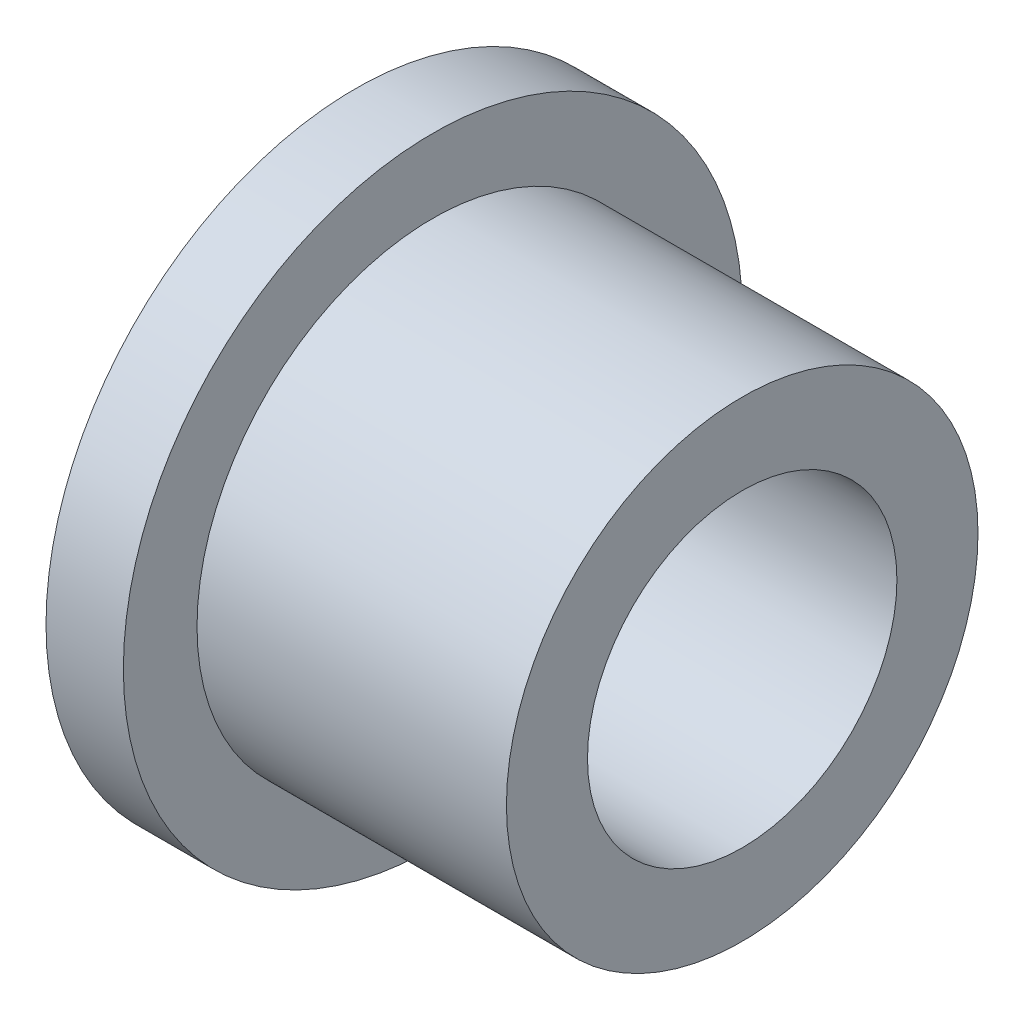
from build123d import *

# Parameters (mm, degrees)
SKETCH1_R           = 6.35
SKETCH1_R_2         = 3.175
BOSS_EXTRUDE1_DEPTH = 1.5875
SKETCH2_R           = 4.8387
SKETCH2_R_2         = 3.175
BOSS_EXTRUDE2_DEPTH = 6.35


with BuildPart() as part:
    # Sketch1 → Boss-Extrude1 (new body)
    with BuildSketch(Plane(origin=(0, 0, 0), x_dir=(0, 0, -1), z_dir=(1, 0, 0))):
        Circle(SKETCH1_R)
        Circle(SKETCH1_R_2, mode=Mode.SUBTRACT)
    extrude(amount=BOSS_EXTRUDE1_DEPTH)

    # Sketch2 → Boss-Extrude2 (add)
    with BuildSketch(Plane(origin=(1.5875, 0, 0), x_dir=(0, 0, -1), z_dir=(1, 0, 0))):
        Circle(SKETCH2_R)
        Circle(SKETCH2_R_2, mode=Mode.SUBTRACT)
    extrude(amount=BOSS_EXTRUDE2_DEPTH)


solid = part.part
